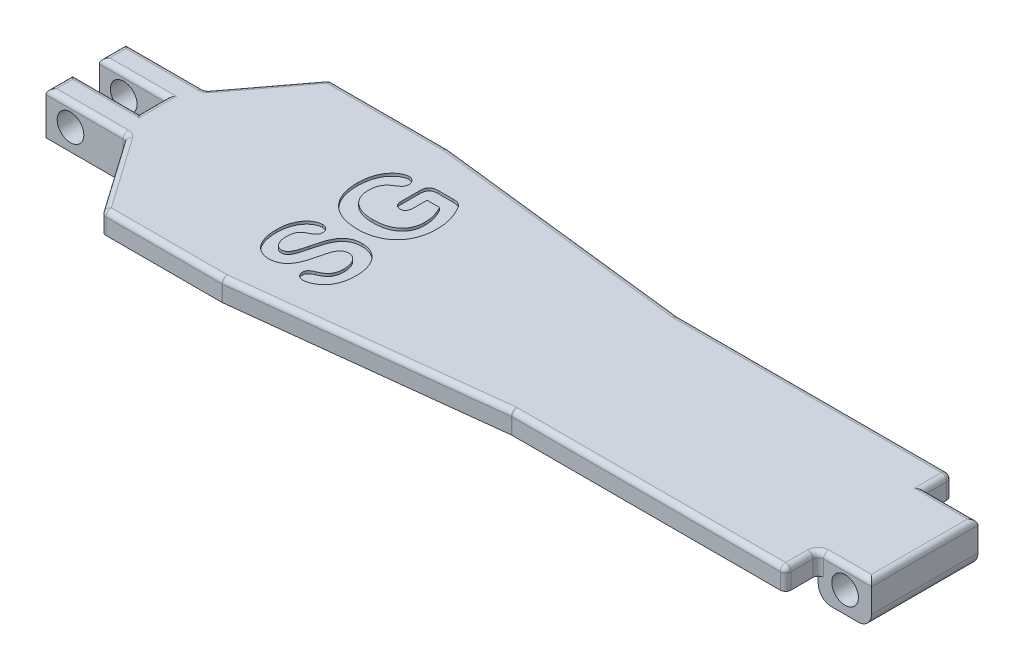
from build123d import *

# Parameters (mm, degrees)
BOSS_EXTRUDE1_DEPTH = 8
SKETCH2_W           = 20
SKETCH2_H           = 40
BOSS_EXTRUDE2_DEPTH = 8
SKETCH3_R           = 5
CUT_EXTRUDE1_DEPTH  = 62.5
FILLET1_R           = 2
FILLET2_R           = 5
CUT_EXTRUDE2_DEPTH  = 1


with BuildPart() as part:
    # Sketch1 → Boss-Extrude1 (new body)
    with BuildSketch(Plane(origin=(0, 0, 0), x_dir=(1, 0, 0), z_dir=(0, 1, 0))):
        Polygon((50, 0), (94.6875, 0), (192.1875, 11.25), (295, 11.25), (295, 23.5), (315, 23.5), (315, 63.5), (295, 63.5), (295, 73.75), (192.1875, 73.75), (94.6875, 85), (50, 85), (30, 58.5), (0, 58.5), (0, 48.5), (25, 48.5), (25, 38.5), (0, 38.5), (0, 28.5), (30, 28.5), align=None)
    extrude(amount=BOSS_EXTRUDE1_DEPTH)

    # Sketch2 → Boss-Extrude2 (add)
    with BuildSketch(Plane.XZ):
        Polygon((0, -48.5), (0, -58.5), (30, -58.5), (30, -28.5), (0, -28.5), (0, -38.5), (25, -38.5), (25, -48.5), align=None)
        with Locations((305, -43.5)):
            Rectangle(SKETCH2_W, SKETCH2_H)
    extrude(amount=BOSS_EXTRUDE2_DEPTH)

    # Sketch3 → Cut-Extrude1 (cut, through all)
    with BuildSketch(Plane.XY.offset(-23.5)):
        with Locations((305.07822106, 0)):
            Circle(SKETCH3_R)
        with Locations((9.196879856, 0)):
            Circle(SKETCH3_R)
    extrude(amount=-CUT_EXTRUDE1_DEPTH, mode=Mode.SUBTRACT)

    # Fillet1
    fillet1_edges = [part.edges().sort_by_distance(p)[0] for p in [
        (143.4375, 8, -79.375),
        (72.34375, 8, -85),
        (40, 8, -71.75),
        (15, 8, -58.5),
        (0, 8, -53.5),
        (12.5, 8, -48.5),
        (25, 8, -43.5),
        (12.5, 8, -38.5),
        (295, 4, -23.5),
        (295, 4, -11.25),
        (192.1875, 4, -11.25),
        (94.6875, 4, 0),
        (50, 4, 0),
        (30, 4, -28.5),
        (30, 4, -58.5),
        (50, 4, -85),
        (94.6875, 4, -85),
        (192.1875, 4, -73.75),
        (295, 4, -73.75),
        (0, 8, -33.5),
        (15, 8, -28.5),
        (295, 8, -68.625),
        (40, 8, -14.25),
        (72.34375, 8, 0),
        (143.4375, 8, -5.625),
        (243.59375, 8, -11.25),
        (295, 8, -17.375),
        (305, 8, -23.5),
        (315, 8, -43.5),
        (305, 8, -63.5),
        (243.59375, 8, -73.75),
    ]]
    fillet(fillet1_edges, radius=FILLET1_R)

    # Fillet2
    fillet2_edges = [part.edges().sort_by_distance(p)[0] for p in [
        (295, -8, -43.5),
        (315, -8, -43.5),
    ]]
    fillet(fillet2_edges, radius=FILLET2_R)

    # Sketch4 → Cut-Extrude2 (cut)
    with BuildSketch(Plane(origin=(0, 8, 0), x_dir=(1, 0, 0), z_dir=(0, 1, 0))):
        with BuildLine():
            add(Edge.make_bspline(
                [(109.745008427, 37.489834609), (109.965868222, 37.485008203), (110.40266134, 37.475463047), (111.048662646, 37.40924705), (111.676988693, 37.303955631), (112.289053289, 37.158936371), (112.881657529, 36.96382019), (113.458322421, 36.727154965), (114.021780222, 36.455359968), (114.561075531, 36.128471357), (115.080566466, 35.76983698), (115.570674784, 35.366265754), (116.034069135, 34.92701081), (116.469514548, 34.446937077), (116.865485915, 33.920480343), (117.243953303, 33.363979261), (117.588805868, 32.763955795), (117.90513897, 32.126572183), (118.185077477, 31.452585998), (118.430873831, 30.748138649), (118.64397932, 30.013512006), (118.81178369, 29.24789153), (118.940480177, 28.451496901), (119.032829101, 27.62434897), (119.094163964, 26.766151983), (119.099652231, 26.183301515), (119.102430302, 25.888272109)],
                knots=[0, 0, 0, 0, 0.000662524, 0.00131027, 0.001946032, 0.002572766, 0.003195351, 0.00381556, 0.004441855, 0.005069903, 0.005705449, 0.006334152, 0.006972421, 0.00761961, 0.008275886, 0.008947059, 0.009637497, 0.010350248, 0.011080416, 0.011825364, 0.012587556, 0.013373717, 0.014175168, 0.015006642, 0.01586996, 0.016754901, 0.016754901, 0.016754901, 0.016754901], degree=3))
            add(Edge.make_bspline(
                [(119.102430302, 25.888272109), (119.095806861, 25.536612509), (119.082802071, 24.846146745), (119.010343457, 23.833918229), (118.871890736, 22.870325804), (118.694043886, 21.950925462), (118.454790125, 21.07918984), (118.158328858, 20.256851714), (117.824480314, 19.47552336), (117.54664604, 18.991317452), (117.409070927, 18.751553359)],
                knots=[0, 0, 0, 0, 0.001055094, 0.002071624, 0.003041966, 0.003973901, 0.004879397, 0.005750456, 0.006595263, 0.007423904, 0.007423904, 0.007423904, 0.007423904], degree=3))
            add(Edge.make_bspline(
                [(117.409070927, 18.751553359), (117.203697371, 18.44122173), (116.795782425, 17.824838041), (116.048364609, 16.998140502), (115.209730727, 16.257941284), (114.287370397, 15.622086566), (113.326464029, 15.103888584), (112.360351058, 14.722100073), (111.402672471, 14.487066247), (110.765746498, 14.454831283), (110.453992802, 14.439053359)],
                knots=[0, 0, 0, 0, 0.001115084, 0.00221479, 0.003331536, 0.004464397, 0.00556803, 0.006599546, 0.007574529, 0.008509279, 0.008509279, 0.008509279, 0.008509279], degree=3))
            add(Edge.make_bspline(
                [(110.453992802, 14.439053359), (110.279249821, 14.447962892), (109.937965858, 14.465363766), (109.447779487, 14.605016686), (108.999848692, 14.833627484), (108.595974711, 15.141169414), (108.262763833, 15.526565575), (108.017879772, 15.96920938), (107.863209923, 16.46218111), (107.848368153, 16.808976173), (107.840711552, 16.987881484)],
                knots=[0, 0, 0, 0, 0.000523587, 0.001022598, 0.001515239, 0.002025038, 0.002536014, 0.003031712, 0.003534015, 0.004069274, 0.004069274, 0.004069274, 0.004069274], degree=3))
            add(Edge.make_bspline(
                [(107.840711552, 16.987881484), (107.846211418, 17.133314521), (107.856870319, 17.415167963), (107.976496559, 17.817750966), (108.157762206, 18.188673191), (108.426451115, 18.52201057), (108.762479343, 18.825368663), (109.170686323, 19.102184276), (109.64408584, 19.361344156), (109.995175188, 19.499622301), (110.178602177, 19.571865859)],
                knots=[0, 0, 0, 0, 0.000435017, 0.000843075, 0.001249236, 0.001666529, 0.002118613, 0.00260296, 0.003143072, 0.003733969, 0.003733969, 0.003733969, 0.003733969], degree=3))
            add(Edge.make_bspline(
                [(110.178602177, 19.571865859), (110.4000593, 19.66780581), (110.827501502, 19.852982893), (111.435450635, 20.149487122), (111.978383023, 20.467950351), (112.478292173, 20.792897702), (112.935451235, 21.15702686), (113.332558472, 21.600418036), (113.70029943, 22.099245701), (114.017914741, 22.675422474), (114.286522447, 23.329306057), (114.467954161, 24.079581353), (114.588080719, 24.917583074), (114.597504614, 25.50889323), (114.602430302, 25.817959609)],
                knots=[0, 0, 0, 0, 0.00072403, 0.001397476, 0.002027597, 0.00261101, 0.003185707, 0.003774566, 0.004391027, 0.005041523, 0.005743329, 0.006505048, 0.007351094, 0.008277542, 0.008277542, 0.008277542, 0.008277542], degree=3))
            add(Edge.make_bspline(
                [(114.602430302, 25.817959609), (114.599768325, 26.036866113), (114.594553041, 26.465742541), (114.53293751, 27.091774018), (114.442047113, 27.687728945), (114.306711204, 28.249571626), (114.136155152, 28.780336607), (113.931570277, 29.281489844), (113.686444005, 29.751789463), (113.398757569, 30.181975694), (113.089211582, 30.573849895), (112.763912426, 30.924191973), (112.408861249, 31.21264574), (112.036056978, 31.447960631), (111.649456213, 31.6409166), (111.239057379, 31.765857121), (110.813364611, 31.855597698), (110.520894133, 31.861718009), (110.371961552, 31.864834609)],
                knots=[0, 0, 0, 0, 0.000656485, 0.001286171, 0.001885347, 0.002463766, 0.00301781, 0.003556426, 0.004085849, 0.004605883, 0.00510644, 0.00558307, 0.006036974, 0.006474234, 0.00690401, 0.00732836, 0.007758136, 0.008204065, 0.008204065, 0.008204065, 0.008204065], degree=3))
            add(Edge.make_bspline(
                [(110.371961552, 31.864834609), (110.142201406, 31.854293116), (109.699303457, 31.83397277), (109.070233066, 31.657236036), (108.504541667, 31.375397853), (108.023779604, 30.962855612), (107.601348801, 30.474043121), (107.239864409, 29.909681323), (106.920693621, 29.286712284), (106.657815342, 28.58400117), (106.419950307, 27.790329948), (106.173817123, 26.887616147), (105.92499435, 25.862691996), (105.759712162, 25.138482467), (105.672742802, 24.757412734)],
                knots=[0, 0, 0, 0, 0.000688046, 0.001326315, 0.00194475, 0.002568931, 0.003212743, 0.00387744, 0.004574484, 0.005308989, 0.006124474, 0.007059774, 0.008115665, 0.009288273, 0.009288273, 0.009288273, 0.009288273], degree=3))
            add(Edge.make_bspline(
                [(105.672742802, 24.757412734), (105.549241753, 24.258500066), (105.31169716, 23.298880629), (104.913610747, 21.927935401), (104.462311419, 20.692006634), (104.002515938, 19.563894944), (103.467662184, 18.55623241), (102.848881209, 17.65895568), (102.13532635, 16.875159544), (101.467740409, 16.310564494), (100.888700504, 15.926992963), (100.431319599, 15.673703239), (99.947274372, 15.460686915), (99.436030543, 15.293145975), (98.901479918, 15.15823402), (98.341892602, 15.057554763), (97.756068847, 14.998376294), (97.356472184, 14.992714542), (97.153211552, 14.989834609)],
                knots=[0, 0, 0, 0, 0.001541918, 0.002965758, 0.004279839, 0.005487781, 0.006617607, 0.007695254, 0.008748802, 0.009788606, 0.01030864, 0.010830519, 0.011355252, 0.011892592, 0.012442563, 0.013008045, 0.013596905, 0.014206534, 0.014206534, 0.014206534, 0.014206534], degree=3))
            add(Edge.make_bspline(
                [(97.153211552, 14.989834609), (96.957655026, 14.991927014), (96.571278709, 14.996061141), (96.000510593, 15.067868028), (95.444058162, 15.160188931), (94.90778475, 15.313381998), (94.385321868, 15.492230044), (93.877959726, 15.71479735), (93.393751148, 15.98778018), (92.922250555, 16.290158808), (92.477891133, 16.638252341), (92.053500213, 17.020447778), (91.654682186, 17.439476196), (91.294879, 17.903658099), (90.942194363, 18.386594152), (90.634138888, 18.920147656), (90.3494408, 19.486732104), (89.98936735, 20.295976969), (89.630743838, 21.392924699), (89.319297691, 22.801670278), (89.139805844, 24.321158113), (89.11515446, 25.370221032), (89.102430302, 25.911709609)],
                knots=[0, 0, 0, 0, 0.000586201, 0.001158203, 0.001723686, 0.002276645, 0.002828858, 0.003379764, 0.003935787, 0.004494859, 0.005058609, 0.005626968, 0.006207253, 0.006791078, 0.007387757, 0.007999746, 0.008636506, 0.009289741, 0.010655328, 0.012089738, 0.01361233, 0.015236656, 0.015236656, 0.015236656, 0.015236656], degree=3))
            add(Edge.make_bspline(
                [(89.102430302, 25.911709609), (89.10967204, 26.343672274), (89.123662995, 27.178219271), (89.248548341, 28.384958991), (89.449038184, 29.501218754), (89.736608772, 30.526532), (90.098809486, 31.4618485), (90.504588083, 32.319358475), (90.969038222, 33.093476792), (91.486589301, 33.778183426), (92.032795574, 34.382079235), (92.605719359, 34.891129002), (93.179938936, 35.329092613), (93.775222606, 35.665324165), (94.368748057, 35.934118742), (94.959154957, 36.11962108), (95.542829415, 36.240298959), (95.929987258, 36.253045446), (96.121961552, 36.259365859)],
                knots=[0, 0, 0, 0, 0.001295571, 0.002503029, 0.003635042, 0.004694228, 0.005692078, 0.00664079, 0.007537141, 0.008394954, 0.009212016, 0.009975491, 0.01069151, 0.011373945, 0.012021824, 0.012642613, 0.013227524, 0.013802818, 0.013802818, 0.013802818, 0.013802818], degree=3))
            add(Edge.make_bspline(
                [(96.121961552, 36.259365859), (96.292785096, 36.250206427), (96.630125776, 36.23211847), (97.122095411, 36.091010585), (97.582847245, 35.858005367), (98.006984838, 35.544926725), (98.36763799, 35.1640104), (98.642581436, 34.728981281), (98.799152, 34.238399193), (98.8188807, 33.89716089), (98.828992802, 33.722256484)],
                knots=[0, 0, 0, 0, 0.000511916, 0.001010927, 0.001521904, 0.002053947, 0.002584536, 0.003087009, 0.003585469, 0.004109613, 0.004109613, 0.004109613, 0.004109613], degree=3))
            add(Edge.make_bspline(
                [(98.828992802, 33.722256484), (98.822685037, 33.567766225), (98.810782225, 33.27624164), (98.741114501, 32.86335309), (98.597393369, 32.513184513), (98.400544661, 32.208592972), (98.134367465, 31.942901562), (97.811940172, 31.670270116), (97.422272148, 31.386164804), (97.131040645, 31.204692814), (96.977430302, 31.108975234)],
                knots=[0, 0, 0, 0, 0.000463817, 0.000875227, 0.001248437, 0.001591348, 0.001956044, 0.002371688, 0.002858052, 0.003400922, 0.003400922, 0.003400922, 0.003400922], degree=3))
            add(Edge.make_bspline(
                [(96.977430302, 31.108975234), (96.695339866, 30.971665305), (96.15101944, 30.706712688), (95.405880819, 30.236498183), (94.765437192, 29.716864968), (94.294681071, 29.251977638), (93.970700793, 28.841967193), (93.772997329, 28.48419358), (93.605959858, 28.086450597), (93.461997301, 27.648433796), (93.360085191, 27.164791587), (93.2851094, 26.638218888), (93.237959038, 26.068795728), (93.231017032, 25.675474117), (93.227430302, 25.472256484)],
                knots=[0, 0, 0, 0, 0.000940754, 0.001815274, 0.002636109, 0.0034109, 0.003795303, 0.004199388, 0.004632546, 0.005088374, 0.005580282, 0.006113099, 0.006683388, 0.007293016, 0.007293016, 0.007293016, 0.007293016], degree=3))
            add(Edge.make_bspline(
                [(93.227430302, 25.472256484), (93.239661788, 25.098478352), (93.263004055, 24.385169297), (93.442304907, 23.368872558), (93.753211656, 22.466145332), (94.117461226, 21.800345876), (94.465025585, 21.346880779), (94.728301162, 21.047307152), (95.010831323, 20.800505653), (95.306672677, 20.598961814), (95.613567042, 20.440019983), (95.93241556, 20.317440442), (96.268010475, 20.255514181), (96.494807277, 20.245063714), (96.608289677, 20.239834609)],
                knots=[0, 0, 0, 0, 0.001120995, 0.00213928, 0.003082493, 0.003974293, 0.004400862, 0.004795011, 0.005168727, 0.005523014, 0.005866325, 0.006203736, 0.006543882, 0.006884533, 0.006884533, 0.006884533, 0.006884533], degree=3))
            add(Edge.make_bspline(
                [(96.608289677, 20.239834609), (96.747523277, 20.244779789), (97.021507122, 20.254510913), (97.415591046, 20.351358379), (97.780057766, 20.505344571), (98.113242065, 20.721384557), (98.417143207, 20.993769821), (98.69676379, 21.314132957), (98.964932232, 21.670393833), (99.269159027, 22.214881699), (99.604830387, 22.923212251), (99.855581108, 23.687806322), (100.052337021, 24.370313797), (100.216356616, 25.027303661), (100.425890222, 25.822040592), (100.5646467, 26.401619656), (100.639539677, 26.714443984)],
                knots=[0, 0, 0, 0, 0.000417046, 0.000820663, 0.001209197, 0.001599275, 0.002006069, 0.002429407, 0.002873561, 0.003340881, 0.004297683, 0.005220455, 0.00575085, 0.006428742, 0.007251583, 0.008216531, 0.008216531, 0.008216531, 0.008216531], degree=3))
            add(Edge.make_bspline(
                [(100.639539677, 26.714443984), (100.735495482, 27.113304944), (100.923208696, 27.893575323), (101.227787419, 29.033211126), (101.549486476, 30.113322283), (101.881746228, 31.137837593), (102.23648013, 32.09775036), (102.646586081, 32.978457301), (103.076067956, 33.791759197), (103.550810111, 34.531470905), (104.083080088, 35.192977304), (104.668977078, 35.787817479), (105.332280584, 36.29005118), (106.055204439, 36.726938795), (106.857460907, 37.075270336), (107.746764243, 37.319020631), (108.71856382, 37.466724348), (109.394850791, 37.481950858), (109.745008427, 37.489834609)],
                knots=[0, 0, 0, 0, 0.001230692, 0.002407537, 0.003538411, 0.004611253, 0.005638567, 0.006606003, 0.007523515, 0.008396267, 0.009238143, 0.010066783, 0.01089418, 0.011727222, 0.012595853, 0.013508563, 0.014486394, 0.015536269, 0.015536269, 0.015536269, 0.015536269], degree=3))
        make_face()
        with BuildLine():
            Line((106.862195927, 68.989834609), (112.411024052, 68.989834609))
            add(Edge.make_bspline(
                [(112.411024052, 68.989834609), (112.586920487, 68.988529368), (112.919727965, 68.986059767), (113.39116016, 68.942831249), (113.807531426, 68.882981436), (114.176081797, 68.788947493), (114.507250978, 68.65439294), (114.822296252, 68.487972041), (115.108680351, 68.25733231), (115.487599058, 67.894242697), (115.938124969, 67.326275801), (116.239898349, 66.814347215), (116.401258427, 66.540615859)],
                knots=[0, 0, 0, 0, 0.000527474, 0.000998015, 0.001418994, 0.001788506, 0.002135597, 0.002489592, 0.002852921, 0.003234186, 0.004063261, 0.005016018, 0.005016018, 0.005016018, 0.005016018], degree=3))
            add(Edge.make_bspline(
                [(116.401258427, 66.540615859), (116.625126457, 66.107535002), (117.064329046, 65.257881599), (117.622539394, 63.9682897), (118.097366424, 62.707123926), (118.472546658, 61.454364251), (118.753923884, 60.186948147), (118.962997449, 58.878549078), (119.077401049, 57.515340283), (119.094002805, 56.587688605), (119.102430302, 56.116787734)],
                knots=[0, 0, 0, 0, 0.001462181, 0.002868626, 0.004212775, 0.005503036, 0.006788097, 0.008104945, 0.0094752, 0.010887905, 0.010887905, 0.010887905, 0.010887905], degree=3))
            add(Edge.make_bspline(
                [(119.102430302, 56.116787734), (119.090543259, 55.569316602), (119.067201524, 54.49428676), (118.869144172, 52.919759761), (118.550124584, 51.418339554), (118.096672283, 49.999199337), (117.532634482, 48.662025545), (116.835213348, 47.427939499), (116.032480864, 46.285595398), (115.099335148, 45.259993538), (114.066815316, 44.335588189), (112.924800112, 43.525859108), (111.676795651, 42.835986402), (110.331576881, 42.254570644), (108.893370797, 41.796032965), (107.367170698, 41.480732375), (105.762459377, 41.272545712), (104.663655759, 41.250893635), (104.102430302, 41.239834609)],
                knots=[0, 0, 0, 0, 0.001641891, 0.003224063, 0.004752563, 0.006240579, 0.007687002, 0.009098418, 0.010485222, 0.011866706, 0.013248636, 0.01463544, 0.016057085, 0.017518902, 0.019025445, 0.020576863, 0.022188831, 0.023871706, 0.023871706, 0.023871706, 0.023871706], degree=3))
            add(Edge.make_bspline(
                [(104.102430302, 41.239834609), (103.549152522, 41.25215506), (102.464719221, 41.276303342), (100.872678603, 41.467912174), (99.352156015, 41.781203236), (97.909130038, 42.224922031), (96.556725124, 42.794346258), (95.302264261, 43.478550241), (94.157315125, 44.287923642), (93.118599542, 45.211352257), (92.197753649, 46.255546023), (91.381398831, 47.403980139), (90.693935706, 48.666274974), (90.106557147, 50.024439112), (89.662553709, 51.488359694), (89.331250653, 53.043897266), (89.137791621, 54.69587987), (89.114409161, 55.829170494), (89.102430302, 56.409756484)],
                knots=[0, 0, 0, 0, 0.001659455, 0.003252559, 0.004802771, 0.006311398, 0.007774001, 0.009197938, 0.010589524, 0.011971455, 0.013357764, 0.014757517, 0.016189412, 0.017661993, 0.019189144, 0.020770438, 0.022428237, 0.024169664, 0.024169664, 0.024169664, 0.024169664], degree=3))
            add(Edge.make_bspline(
                [(89.102430302, 56.409756484), (89.110486738, 56.884761909), (89.126176426, 57.809821977), (89.275081259, 59.15627535), (89.518298862, 60.418982592), (89.858154241, 61.592392976), (90.275696452, 62.666172004), (90.735787765, 63.644925916), (91.248689137, 64.518121835), (91.823304156, 65.277069589), (92.427430826, 65.940135316), (93.051379132, 66.515129471), (93.682879332, 67.017001319), (94.337656143, 67.40981022), (94.979528659, 67.717631129), (95.585814696, 67.95401506), (96.162958716, 68.089215372), (96.535437236, 68.111823597), (96.713758427, 68.122647109)],
                knots=[0, 0, 0, 0, 0.0014246, 0.002774369, 0.004057946, 0.005278104, 0.006433709, 0.007510894, 0.008519796, 0.0094655, 0.01036139, 0.011207254, 0.012008939, 0.012776674, 0.013492118, 0.014142931, 0.014725725, 0.015260985, 0.015260985, 0.015260985, 0.015260985], degree=3))
            add(Edge.make_bspline(
                [(96.713758427, 68.122647109), (96.892469881, 68.112012131), (97.242461152, 68.091184424), (97.74803142, 67.940868349), (98.206925585, 67.681218345), (98.612352855, 67.330716871), (98.951260249, 66.912247769), (99.201492453, 66.443685708), (99.356651377, 65.931135349), (99.371933692, 65.574926118), (99.379774052, 65.392178359)],
                knots=[0, 0, 0, 0, 0.000535805, 0.001049328, 0.001566084, 0.002106291, 0.002648022, 0.003172264, 0.003691406, 0.00423834, 0.00423834, 0.00423834, 0.00423834], degree=3))
            add(Edge.make_bspline(
                [(99.379774052, 65.392178359), (99.365076481, 65.186754399), (99.335327033, 64.770954458), (99.092173164, 64.186304662), (98.738169479, 63.649354596), (98.405484984, 63.378699239), (98.237195927, 63.241787734)],
                knots=[0, 0, 0, 0, 0.000614117, 0.001243039, 0.001875254, 0.002522443, 0.002522443, 0.002522443, 0.002522443], degree=3))
            add(Edge.make_bspline(
                [(98.237195927, 63.241787734), (97.968236672, 63.068047273), (97.462561161, 62.741394462), (96.768863783, 62.24934446), (96.171209268, 61.810957968), (95.665832713, 61.395381045), (95.226017053, 60.970743054), (94.847682741, 60.483449484), (94.495838497, 59.93702905), (94.174353269, 59.325865857), (93.914972896, 58.632348378), (93.729541076, 57.851536061), (93.61909014, 56.981285204), (93.60814589, 56.371035104), (93.602430302, 56.052334609)],
                knots=[0, 0, 0, 0, 0.000960455, 0.00180577, 0.002551086, 0.003183519, 0.003767725, 0.004380836, 0.005029323, 0.005715946, 0.006448368, 0.007244208, 0.008118512, 0.009074237, 0.009074237, 0.009074237, 0.009074237], degree=3))
            add(Edge.make_bspline(
                [(93.602430302, 56.052334609), (93.612196343, 55.717994725), (93.631289147, 55.064353638), (93.757951571, 54.110694496), (93.984405953, 53.214804394), (94.28621129, 52.37130822), (94.682154403, 51.587735467), (95.159495042, 50.863482338), (95.714112519, 50.197777644), (96.344012086, 49.588960316), (97.058215845, 49.050057598), (97.845381112, 48.57439231), (98.710187938, 48.168970856), (99.645231704, 47.829878934), (100.648754535, 47.571096147), (101.703495318, 47.375305016), (102.812995762, 47.265294231), (103.568995219, 47.248454074), (103.955945927, 47.239834609)],
                knots=[0, 0, 0, 0, 0.001003049, 0.001960981, 0.002879016, 0.003770585, 0.004643179, 0.00550612, 0.006367369, 0.007237599, 0.008128244, 0.009045699, 0.009991893, 0.010989089, 0.012025155, 0.013097421, 0.014204594, 0.015365475, 0.015365475, 0.015365475, 0.015365475], degree=3))
            add(Edge.make_bspline(
                [(103.955945927, 47.239834609), (104.370259443, 47.245824229), (105.177037417, 47.257487602), (106.350267841, 47.369619526), (107.448839792, 47.556344602), (108.475325137, 47.811862941), (109.426564196, 48.145868941), (110.307325659, 48.55094774), (111.115063007, 49.031320834), (111.842907128, 49.591700766), (112.496318874, 50.211717165), (113.062972428, 50.896180703), (113.541473772, 51.639621928), (113.928588558, 52.443736429), (114.234484672, 53.301837317), (114.450826589, 54.21926211), (114.581633605, 55.195008638), (114.595382193, 55.866369598), (114.602430302, 56.210537734)],
                knots=[0, 0, 0, 0, 0.001242685, 0.002419836, 0.003531466, 0.004583089, 0.005589351, 0.006551466, 0.007487005, 0.008402288, 0.009301601, 0.010183861, 0.011061536, 0.01194729, 0.012855399, 0.013789119, 0.01477028, 0.015802346, 0.015802346, 0.015802346, 0.015802346], degree=3))
            add(Edge.make_bspline(
                [(114.602430302, 56.210537734), (114.595544271, 56.54869563), (114.581980693, 57.214773199), (114.478505388, 58.197398383), (114.31824709, 59.150287186), (114.077643773, 60.076144284), (113.7818953, 60.990919132), (113.428959471, 61.905955214), (113.018709134, 62.826407246), (112.708744151, 63.43260441), (112.551649052, 63.739834609)],
                knots=[0, 0, 0, 0, 0.001014281, 0.001997854, 0.002961146, 0.003910456, 0.004864743, 0.005844082, 0.006851299, 0.007886353, 0.007886353, 0.007886353, 0.007886353], degree=3))
            Line((112.551649052, 63.739834609), (107.852430302, 63.739834609))
            Line((107.852430302, 63.739834609), (107.852430302, 59.146084609))
            add(Edge.make_bspline(
                [(107.852430302, 59.146084609), (107.84816764, 58.885996833), (107.840186342, 58.399015234), (107.747209595, 57.716288621), (107.594453945, 57.132482051), (107.37557177, 56.641481993), (107.066908521, 56.255306402), (106.670284702, 55.971885794), (106.175976276, 55.814250405), (105.820341852, 55.797530384), (105.631727177, 55.788662734)],
                knots=[0, 0, 0, 0, 0.000779847, 0.001460166, 0.00206143, 0.002585673, 0.003060607, 0.003527192, 0.004027474, 0.00459244, 0.00459244, 0.00459244, 0.00459244], degree=3))
            add(Edge.make_bspline(
                [(105.631727177, 55.788662734), (105.47234105, 55.79473677), (105.162908906, 55.806528901), (104.724932388, 55.951065886), (104.328466871, 56.170952966), (103.982204935, 56.478091267), (103.697206959, 56.861821187), (103.498986806, 57.319100469), (103.372881186, 57.834666415), (103.359433375, 58.19998314), (103.352430302, 58.390225234)],
                knots=[0, 0, 0, 0, 0.000476378, 0.000924841, 0.001368183, 0.001828992, 0.002302443, 0.002790286, 0.003314692, 0.003884529, 0.003884529, 0.003884529, 0.003884529], degree=3))
            Line((103.352430302, 58.390225234), (103.352430302, 65.028897109))
            add(Edge.make_bspline(
                [(103.352430302, 65.028897109), (103.353174505, 65.224366524), (103.354613234, 65.602257356), (103.407669485, 66.143181045), (103.465438508, 66.639964978), (103.564119923, 67.091089819), (103.707901505, 67.503892478), (103.922415304, 67.875480496), (104.210261408, 68.199291375), (104.56242226, 68.490492443), (105.00650991, 68.719629586), (105.541971732, 68.881224102), (106.17179323, 68.969823886), (106.621680712, 68.982863484), (106.862195927, 68.989834609)],
                knots=[0, 0, 0, 0, 0.000586055, 0.001132989, 0.001629379, 0.002085696, 0.002515712, 0.002935792, 0.003363527, 0.003809186, 0.004299311, 0.004851587, 0.005479716, 0.006201276, 0.006201276, 0.006201276, 0.006201276], degree=3))
        make_face()
    extrude(amount=-CUT_EXTRUDE2_DEPTH, mode=Mode.SUBTRACT)


solid = part.part
